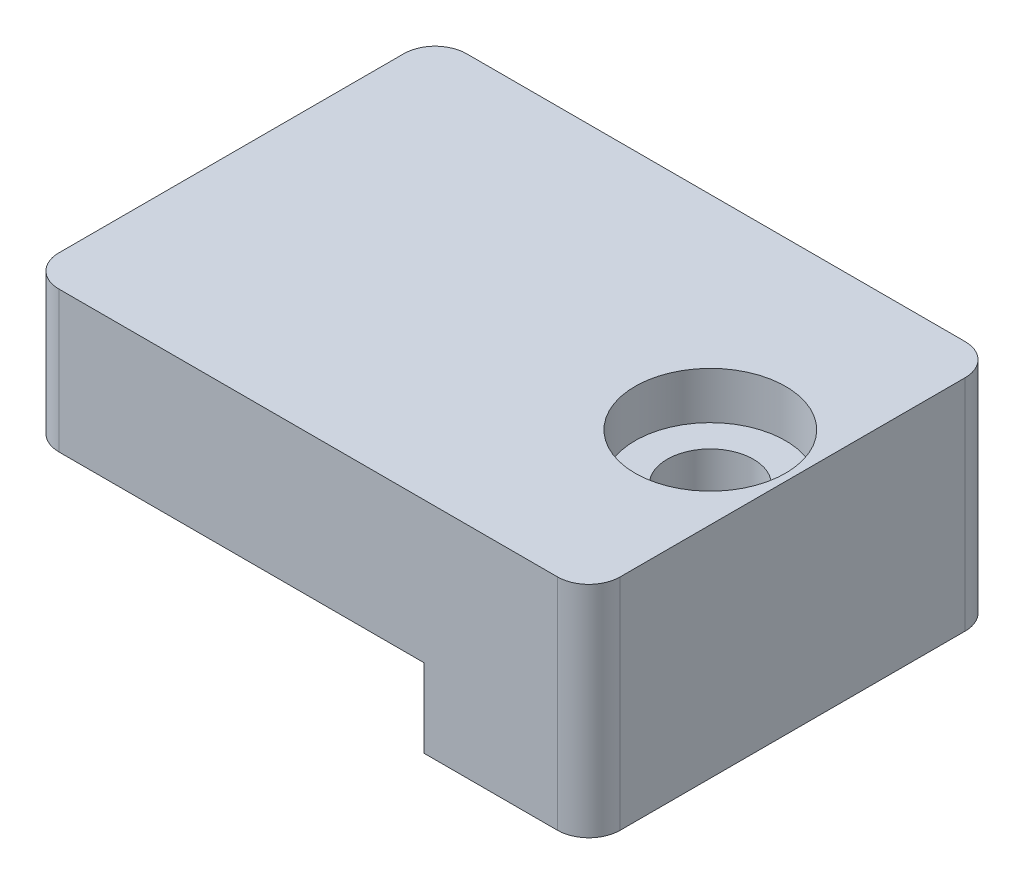
from build123d import *

# Parameters (mm, degrees)
BOSS_EXTRUDE1_DEPTH             = 26
FILLET2_R                       = 2
CBORE_FOR_M5_SBHCS1_D           = 5.5
CBORE_FOR_M5_SBHCS1_CBORE_D     = 9.6
CBORE_FOR_M5_SBHCS1_CBORE_DEPTH = 3
SKETCH10_W                      = 8.75
SKETCH10_H                      = 4.2
SKETCH10_W_2                    = 16
SKETCH10_H_2                    = 2.55
CUT_EXTRUDE3_DEPTH              = 23.3
FILLET6_R                       = 3.175


with BuildPart() as part:
    # Sketch1 → Boss-Extrude1 (new body)
    with BuildSketch(Plane.XY):
        Polygon((-25.3, 0), (-25.3, -9), (0, -9), (0, -14), (10.5, -14), (10.5, 0), (0, 0), align=None)
    extrude(amount=BOSS_EXTRUDE1_DEPTH)

    # Fillet2
    fillet2_edges = [part.edges().sort_by_distance(p)[0] for p in [
        (10.5, -7, 26),
        (10.5, -7, 0),
        (-25.3, -4.5, 26),
        (-25.3, -4.5, 0),
    ]]
    fillet(fillet2_edges, radius=FILLET2_R)

    # CBORE for M5 SBHCS1 (through all)
    with Locations(Plane(origin=(0, 0, 0), x_dir=(1, 0, 0), z_dir=(0, 1, 0))):
        with Locations((5.25, -13)):
            CounterBoreHole(CBORE_FOR_M5_SBHCS1_D / 2, CBORE_FOR_M5_SBHCS1_CBORE_D / 2, CBORE_FOR_M5_SBHCS1_CBORE_DEPTH)

    # Sketch10 → Cut-Extrude3 (cut)
    with BuildSketch(Plane.ZY.offset(25.3)):
        with Locations((13, -4.35)):
            Rectangle(SKETCH10_W, SKETCH10_H)
        with Locations((13, -7.725)):
            Rectangle(SKETCH10_W_2, SKETCH10_H_2)
    extrude(amount=-CUT_EXTRUDE3_DEPTH, mode=Mode.SUBTRACT)

    # Fillet6
    fillet6_edges = [part.edges().sort_by_distance(p)[0] for p in [
        (-2, -7.725, 21),
        (-2, -7.725, 5),
        (-2, -4.35, 8.625),
        (-2, -4.35, 17.375),
    ]]
    fillet(fillet6_edges, radius=FILLET6_R)


solid = part.part
